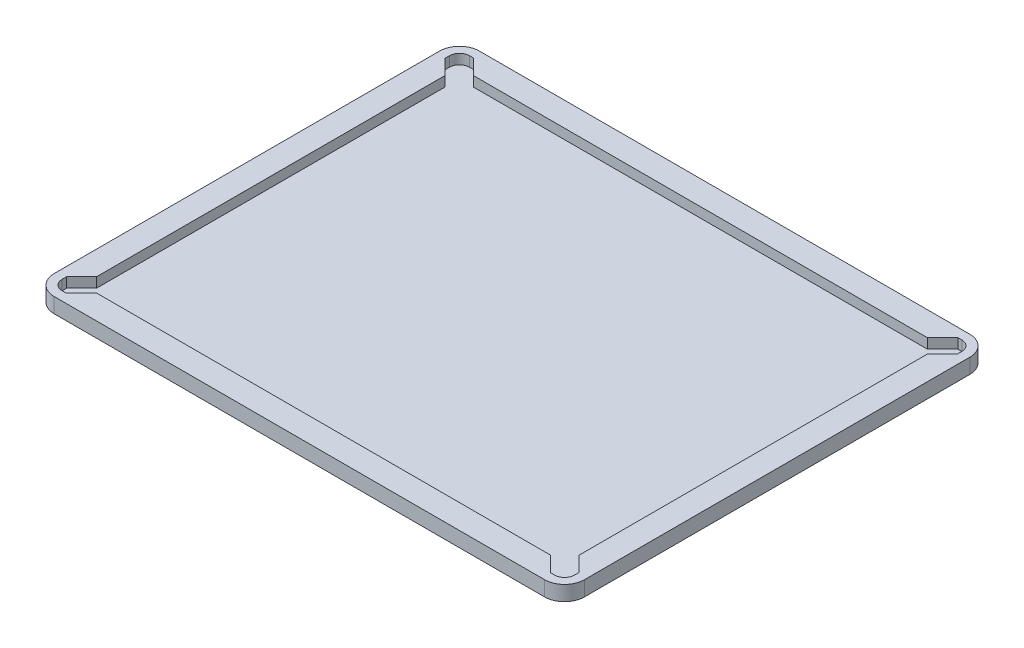
from build123d import *

# Parameters (mm, degrees)
SKETCH1_W           = 266
SKETCH1_H           = 213.3
BOSS_EXTRUDE1_DEPTH = 7.5
SKETCH2_W           = 242
SKETCH2_H           = 189
CUT_EXTRUDE1_DEPTH  = 5
CUT_EXTRUDE2_DEPTH  = 5
FILLET1_R           = 5
FILLET2_R           = 10


with BuildPart() as part:
    # Sketch1 → Boss-Extrude1 (new body)
    with BuildSketch(Plane(origin=(0, 0, 0), x_dir=(1, 0, 0), z_dir=(0, 1, 0))):
        with Locations((133, 106.65)):
            Rectangle(SKETCH1_W, SKETCH1_H)
    extrude(amount=BOSS_EXTRUDE1_DEPTH)

    # Sketch2 → Cut-Extrude1 (cut)
    with BuildSketch(Plane(origin=(0, 7.5, 0), x_dir=(1, 0, 0), z_dir=(0, 1, 0))):
        with Locations((133, 106.65)):
            Rectangle(SKETCH2_W, SKETCH2_H)
    extrude(amount=-CUT_EXTRUDE1_DEPTH, mode=Mode.SUBTRACT)

    # Sketch3 → Cut-Extrude2 (cut)
    with BuildSketch(Plane(origin=(0, 7.5, 0), x_dir=(1, 0, 0), z_dir=(0, 1, 0))):
        Polygon((12, 194.078932188), (4.5, 201.578932188), (4.5, 208.8), (11.421067812, 208.8), (19.071067812, 201.15), align=None)
        Polygon((19.071067812, 12.15), (12, 19.221067812), (4.5, 11.721067812), (4.5, 4.5), (11.421067812, 4.5), align=None)
        Polygon((254, 19.221067812), (261.5, 11.721067812), (261.5, 4.5), (254.578932188, 4.5), (246.928932188, 12.15), align=None)
        Polygon((246.928932188, 201.15), (254, 194.078932188), (261.5, 201.578932188), (261.5, 208.8), (254.578932188, 208.8), align=None)
    extrude(amount=-CUT_EXTRUDE2_DEPTH, mode=Mode.SUBTRACT)

    # Fillet1
    fillet1_edges = [part.edges().sort_by_distance(p)[0] for p in [
        (4.5, 5, -208.8),
        (4.5, 5, -4.5),
        (261.5, 5, -4.5),
        (261.5, 5, -208.8),
    ]]
    fillet(fillet1_edges, radius=FILLET1_R)

    # Fillet2
    fillet2_edges = [part.edges().sort_by_distance(p)[0] for p in [
        (0, 3.75, -213.3),
        (266, 3.75, -213.3),
        (266, 3.75, 0),
        (0, 3.75, 0),
    ]]
    fillet(fillet2_edges, radius=FILLET2_R)


solid = part.part
